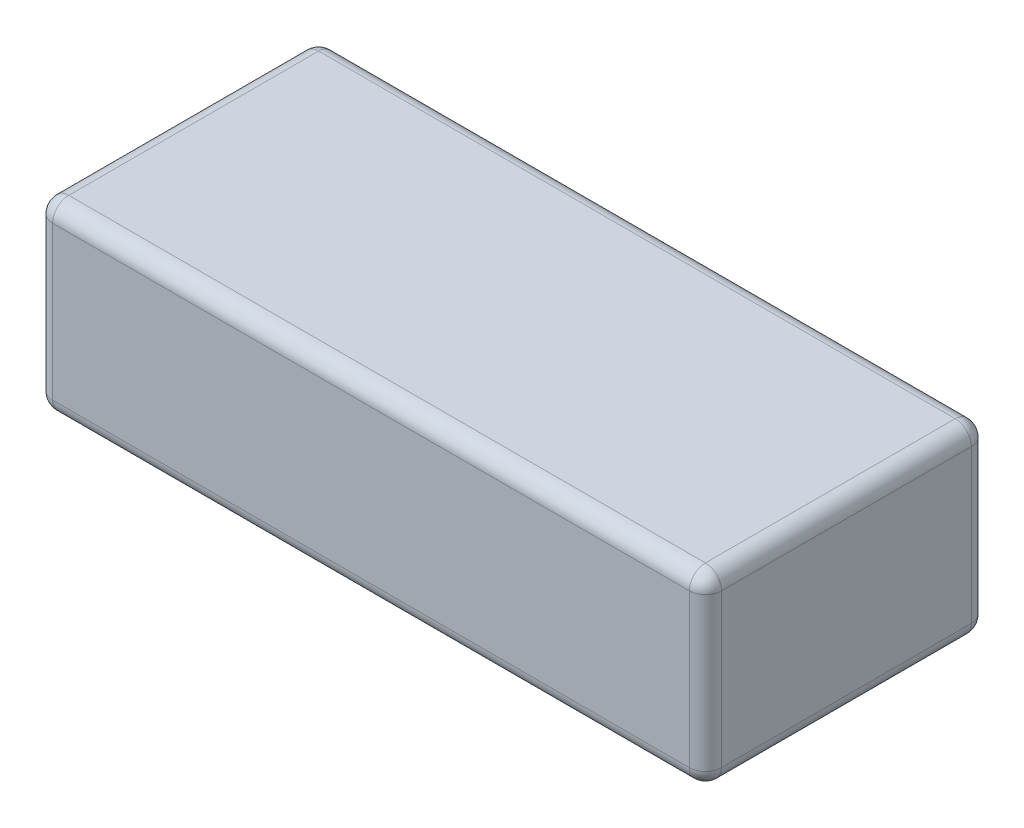
from build123d import *

# Parameters (mm, degrees)
SKETCH_1_W      = 83
SKETCH_1_H      = 35
EXTRUDE_1_DEPTH = 23
FILLET_1_R      = 2


with BuildPart() as part:
    # 草图1 → 凸台-拉伸1 (new body)
    with BuildSketch(Plane(origin=(0, 0, 0), x_dir=(1, 0, 0), z_dir=(0, 1, 0))):
        Rectangle(SKETCH_1_W, SKETCH_1_H)
    extrude(amount=EXTRUDE_1_DEPTH)

    # 圆角1
    fillet_1_edges = [part.edges().sort_by_distance(p)[0] for p in [
        (-41.5, 23, 0),
        (0, 23, 17.5),
        (41.5, 23, 0),
        (0, 0, 17.5),
        (-41.5, 0, 0),
        (0, 0, -17.5),
        (41.5, 0, 0),
        (0, 23, -17.5),
        (41.5, 11.5, 17.5),
        (-41.5, 11.5, 17.5),
        (-41.5, 11.5, -17.5),
        (41.5, 11.5, -17.5),
    ]]
    fillet(fillet_1_edges, radius=FILLET_1_R)


solid = part.part
